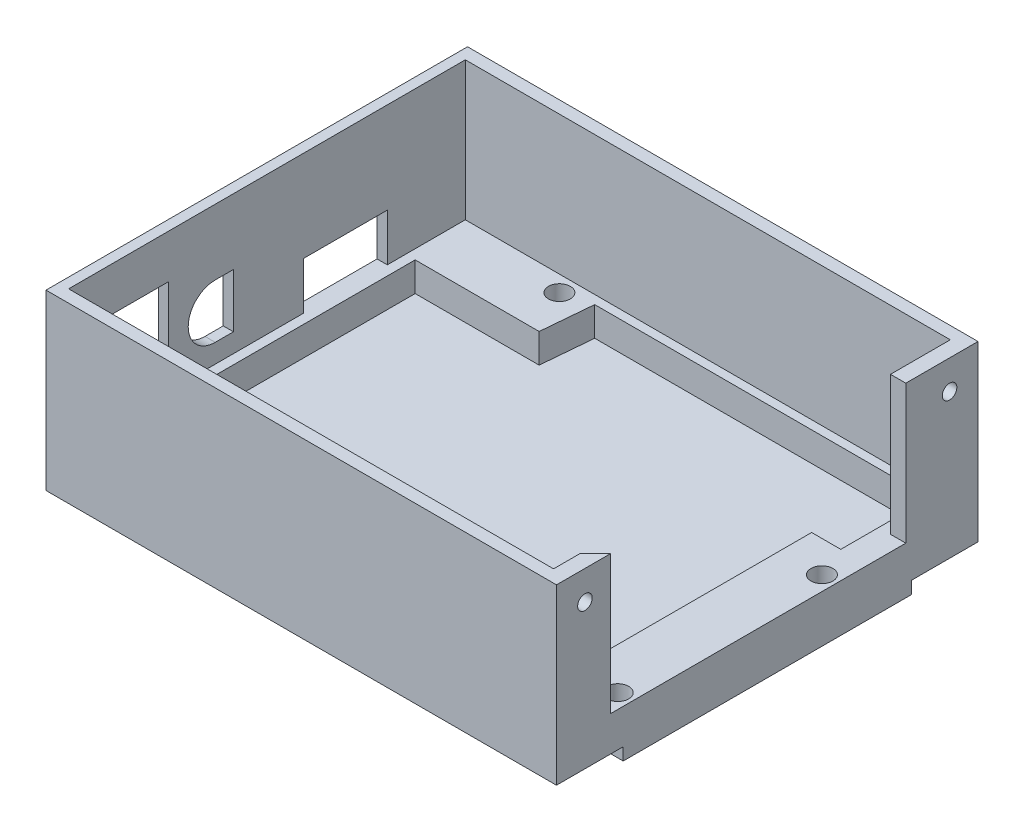
from build123d import *

# Parameters (mm, degrees)
EXTRUDE_1_DEPTH      = 4
SKETCH_3_W           = 73
SKETCH_3_H           = 58
EXTRUDE_2_DEPTH      = 13
EXTRUDE_2_DEPTH_BACK = 4
SKETCH_4_W           = 17
SKETCH_4_H           = 7
EXTRUDE_4_DEPTH      = 4
SKETCH_5_R           = 1.5
CUT_EXTRUDE_1_DEPTH  = 4
EXTRUDE_5_DEPTH      = 4
EXTRUDE_6_DEPTH      = 4
SKETCH_8_W           = 73
SKETCH_8_H           = 58
EXTRUDE_7_DEPTH      = 1
SKETCH_9_W           = 8.5
SKETCH_9_H           = 3.5
CUT_EXTRUDE_2_DEPTH  = 2
CHAMFER_1_SIZE       = 0.5
SKETCH_10_W          = 9
SKETCH_10_H          = 12
CUT_EXTRUDE_3_DEPTH  = 2
CHAMFER_2_SIZE       = 0.5
CHAMFER_3_SIZE       = 0.5
CHAMFER_4_SIZE       = 0.5
CUT_EXTRUDE_4_DEPTH  = 2
CHAMFER_5_SIZE       = 0.5
CHAMFER_6_SIZE       = 0.5
SKETCH_21_W          = 2
SKETCH_21_H          = 58
CUT_EXTRUDE_5_DEPTH  = 19
CUT_EXTRUDE_7_DEPTH  = 13
EXTRUDE_8_DEPTH      = 6
SKETCH_36_W          = 71
SKETCH_36_H          = 39.5
EXTRUDE_9_DEPTH      = 1.5
SKETCH_39_R          = 1
CUT_EXTRUDE_9_DEPTH  = 5
SKETCH_42_W          = 9.25
SKETCH_42_H          = 0.2
CUT_EXTRUDE_10_DEPTH = 72
SKETCH_43_W          = 0.1
SKETCH_43_H          = 23.8
CUT_EXTRUDE_11_DEPTH = 72
CUT_EXTRUDE_12_DEPTH = 0.5
CUT_EXTRUDE_13_DEPTH = 0.5
SKETCH_46_W          = 66.5
SKETCH_46_H          = 54.4
SKETCH_46_W_2        = 66
SKETCH_46_H_2        = 54
CUT_EXTRUDE_14_DEPTH = 19
SKETCH_47_W          = 11.5
SKETCH_47_H          = 6.5
SKETCH_47_W_2        = 8.5
SKETCH_47_H_2        = 3.5
CUT_EXTRUDE_16_DEPTH = 7.5
CUT_EXTRUDE_17_DEPTH = 7.5
SKETCH_51_W          = 10
SKETCH_51_H          = 14.5
SKETCH_51_W_2        = 7.5
SKETCH_51_H_2        = 12
CUT_EXTRUDE_18_DEPTH = 7.5


with BuildPart() as part:
    # 草图1 → 凸台-拉伸1 (new body)
    with BuildSketch(Plane(origin=(0, 0, 0), x_dir=(1, 0, 0), z_dir=(0, 1, 0))):
        Polygon((33, -27), (-33, -27), (-33, 27), (33, 27), (33, 14), (36, 11), (36, -21), (33, -24), align=None)
        Polygon((-31.777777778, 26), (-31.777777778, -26), (31.777777778, -26), (31.777777778, -23.80800866), (35, -20.585786438), (35, 9.543812347), (35, 10.585786438), (31.777777778, 13.80800866), (31.777777778, 26), align=None, mode=Mode.SUBTRACT)
    extrude(amount=-EXTRUDE_1_DEPTH)

    # 草图3 → 凸台-拉伸2 (add, two sides)
    with BuildSketch(Plane(origin=(0, 0, 0), x_dir=(1, 0, 0), z_dir=(0, 1, 0))) as extrude_2_sk:
        with Locations((1.5, 0)):
            Rectangle(SKETCH_3_W, SKETCH_3_H)
        Polygon((33, 27), (33, 14), (36, 11), (36, -21), (33, -24), (33, -27), (-33, -27), (-33, 27), align=None, mode=Mode.SUBTRACT)
    extrude(amount=EXTRUDE_2_DEPTH)
    extrude(extrude_2_sk.sketch, amount=-EXTRUDE_2_DEPTH_BACK)

    # 草图4 → 凸台-拉伸4 (add)
    with BuildSketch(Plane(origin=(0, 0, 0), x_dir=(1, 0, 0), z_dir=(0, 1, 0))):
        with Locations((-23.277777778, 22.5)):
            Rectangle(SKETCH_4_W, SKETCH_4_H)
        Polygon((31.777777778, 13.80800866), (27.777777778, 13.80800866), (27.777777778, -22), (33.585786438, -22), (35, -20.585786438), (35, 10.585786438), align=None)
    extrude(amount=-EXTRUDE_4_DEPTH)

    # 草图5 → 切除-拉伸1 (cut)
    with BuildSketch(Plane(origin=(0, 0, 0), x_dir=(1, 0, 0), z_dir=(0, 1, 0))):
        with Locations((-18, 25)):
            Circle(SKETCH_5_R)
        with Locations((33.5, 9.5)):
            Circle(SKETCH_5_R)
        with Locations((33.5, -18.5)):
            Circle(SKETCH_5_R)
    extrude(amount=-CUT_EXTRUDE_1_DEPTH, mode=Mode.SUBTRACT)

    # 草图6 → 凸台-拉伸5 (add)
    with BuildSketch(Plane.XZ.offset(4)):
        Polygon((31.777777778, 23.80800866), (33.585786438, 22), (30.681782108, 22), align=None)
    extrude(amount=-EXTRUDE_5_DEPTH)

    # 草图7 → 凸台-拉伸6 (add)
    with BuildSketch(Plane(origin=(0, 0, 0), x_dir=(1, 0, 0), z_dir=(0, 1, 0))):
        Polygon((-14.158955627, 26), (-14.777777778, 19), (-14.777777778, 26), align=None)
    extrude(amount=-EXTRUDE_6_DEPTH)

    # 草图8 → 凸台-拉伸7 (add)
    with BuildSketch(Plane.XZ.offset(4)):
        with Locations((1.5, 0)):
            Rectangle(SKETCH_8_W, SKETCH_8_H)
    extrude(amount=EXTRUDE_7_DEPTH)

    # 草图9 → 切除-拉伸2 (cut)
    with BuildSketch(Plane(origin=(-33, 0, 0), x_dir=(0, 0, -1), z_dir=(1, 0, 0))):
        with Locations((10.25, 2.75)):
            Rectangle(SKETCH_9_W, SKETCH_9_H)
    extrude(amount=-CUT_EXTRUDE_2_DEPTH, mode=Mode.SUBTRACT)

    # 倒角1
    chamfer_1_edges = [part.edges().sort_by_distance(p)[0] for p in [
        (-35, 4.5, -10.25),
        (-35, 2.75, -14.5),
        (-35, 1, -10.25),
        (-35, 2.75, -6),
    ]]
    chamfer(chamfer_1_edges, length=CHAMFER_1_SIZE)

    # 草图10 → 切除-拉伸3 (cut)
    with BuildSketch(Plane(origin=(-33, 0, 0), x_dir=(0, 0, -1), z_dir=(1, 0, 0))):
        with Locations((-18.5, 6)):
            Rectangle(SKETCH_10_W, SKETCH_10_H)
    extrude(amount=-CUT_EXTRUDE_3_DEPTH, mode=Mode.SUBTRACT)

    # 倒角2
    chamfer_2_edges = [part.edges().sort_by_distance(p)[0] for p in [
        (-35, 6, 23),
        (-35, 12, 18.5),
        (-35, 6, 14),
        (-35, 0, 18.5),
    ]]
    chamfer(chamfer_2_edges, length=CHAMFER_2_SIZE)

    # 倒角3
    chamfer_3_edges = [part.edges().sort_by_distance(p)[0] for p in [
        (-33, 4.5, -10.25),
        (-33, 1, -10.25),
        (-33, 12, 18.5),
    ]]
    chamfer(chamfer_3_edges, length=CHAMFER_3_SIZE)

    # 倒角4
    chamfer_4_edges = [part.edges().sort_by_distance(p)[0] for p in [
        (-33, 6, 14),
        (-33, 6, 23),
        (-33, 2.75, -6),
        (-33, 2.75, -14.5),
    ]]
    chamfer(chamfer_4_edges, length=CHAMFER_4_SIZE)

    # 草图13 → 切除-拉伸4 (cut)
    with BuildSketch(Plane(origin=(-33, 0, 0), x_dir=(0, 0, -1), z_dir=(1, 0, 0))):
        with BuildLine():
            Line((-6, 8.6), (-7.1, 8.6))
            ThreePointArc((-7.1, 8.6), (-9.4, 6.3), (-7.1, 4))
            Line((-7.1, 4), (-6, 4))
            Line((-6, 4), (-6, 8.6))
        make_face()
    extrude(amount=-CUT_EXTRUDE_4_DEPTH, mode=Mode.SUBTRACT)

    # 倒角5
    chamfer_5_edges = [part.edges().sort_by_distance(p)[0] for p in [
        (-35, 6.3, 6),
        (-35, 4, 6.55),
        (-35, 6.3, 9.4),
        (-35, 8.6, 6.55),
    ]]
    chamfer(chamfer_5_edges, length=CHAMFER_5_SIZE)

    # 倒角6
    chamfer_6_edges = [part.edges().sort_by_distance(p)[0] for p in [
        (-33, 6.3, 6),
        (-33, 8.6, 6.55),
        (-33, 6.3, 9.4),
        (-33, 4, 6.55),
    ]]
    chamfer(chamfer_6_edges, length=CHAMFER_6_SIZE)

    # 草图21 → 切除-拉伸5 (cut, through all)
    with BuildSketch(Plane(origin=(0, 13, 0), x_dir=(1, 0, 0), z_dir=(0, 1, 0))):
        with Locations((37, 0)):
            Rectangle(SKETCH_21_W, SKETCH_21_H)
    extrude(amount=-CUT_EXTRUDE_5_DEPTH, mode=Mode.SUBTRACT)

    # 草图23 → 切除-拉伸7 (cut)
    with BuildSketch(Plane(origin=(0, 13, 0), x_dir=(1, 0, 0), z_dir=(0, 1, 0))):
        Polygon((33, 14), (33, 19), (36, 19), (36, 11), align=None)
    extrude(amount=-CUT_EXTRUDE_7_DEPTH, mode=Mode.SUBTRACT)

    # 草图27 → 凸台-拉伸8 (add)
    with BuildSketch(Plane(origin=(0, 13, 0), x_dir=(1, 0, 0), z_dir=(0, 1, 0))):
        Polygon((33, 19), (36, 19), (36, 29), (-35, 29), (-35, -29), (36, -29), (36, -21), (33, -24), (33, -27), (-33, -27), (-33, 27), (33, 27), align=None)
    extrude(amount=EXTRUDE_8_DEPTH)

    # 草图36 → 凸台-拉伸9 (add)
    with BuildSketch(Plane.XZ.offset(5)):
        with Locations((0.5, 0)):
            Rectangle(SKETCH_36_W, SKETCH_36_H)
    extrude(amount=EXTRUDE_9_DEPTH)

    # 草图39 → 切除-拉伸9 (cut)
    with BuildSketch(Plane(origin=(36, 0, 0), x_dir=(0, 0, -1), z_dir=(1, 0, 0))):
        with Locations((-25, 15)):
            Circle(SKETCH_39_R)
        with Locations((25, 15)):
            Circle(SKETCH_39_R)
    extrude(amount=-CUT_EXTRUDE_9_DEPTH, mode=Mode.SUBTRACT)

    # 草图42 → 切除-拉伸10 (cut, through all)
    with BuildSketch(Plane(origin=(36, 0, 0), x_dir=(0, 0, -1), z_dir=(1, 0, 0))):
        with Locations((-24.375, -4.9)):
            Rectangle(SKETCH_42_W, SKETCH_42_H)
        with Locations((24.375, -4.9)):
            Rectangle(SKETCH_42_W, SKETCH_42_H)
    extrude(amount=-CUT_EXTRUDE_10_DEPTH, mode=Mode.SUBTRACT)

    # 草图43 → 切除-拉伸11 (cut, through all)
    with BuildSketch(Plane(origin=(36, 0, 0), x_dir=(0, 0, -1), z_dir=(1, 0, 0))):
        with Locations((-28.95, 7.1)):
            Rectangle(SKETCH_43_W, SKETCH_43_H)
        with Locations((28.95, 7.1)):
            Rectangle(SKETCH_43_W, SKETCH_43_H)
    extrude(amount=-CUT_EXTRUDE_11_DEPTH, mode=Mode.SUBTRACT)

    # 草图44 → 切除-拉伸12 (cut)
    with BuildSketch(Plane(origin=(36, 0, 0), x_dir=(0, 0, -1), z_dir=(1, 0, 0))):
        Polygon((19.75, -4.8), (28.9, -4.8), (28.9, 19), (19, 19), (19, 0), (-21, 0), (-21, 19), (-28.9, 19), (-28.9, -4.8), (-19.75, -4.8), (-19.75, -6.5), (19.75, -6.5), align=None)
    extrude(amount=-CUT_EXTRUDE_12_DEPTH, mode=Mode.SUBTRACT)

    # 草图45 → 切除-拉伸13 (cut)
    with BuildSketch(Plane.ZY.offset(35)):
        Polygon((28.9, 19), (-28.9, 19), (-28.9, -4.8), (-19.75, -4.8), (-19.75, -6.5), (19.75, -6.5), (19.75, -4.8), (28.9, -4.8), align=None)
    extrude(amount=-CUT_EXTRUDE_13_DEPTH, mode=Mode.SUBTRACT)

    # 草图46 → 切除-拉伸14 (cut)
    with BuildSketch(Plane(origin=(0, 19, 0), x_dir=(1, 0, 0), z_dir=(0, 1, 0))):
        with Locations((0.15, 0)):
            Rectangle(SKETCH_46_W, SKETCH_46_H)
        Rectangle(SKETCH_46_W_2, SKETCH_46_H_2, mode=Mode.SUBTRACT)
    extrude(amount=-CUT_EXTRUDE_14_DEPTH, mode=Mode.SUBTRACT)

    # 草图47 → 切除-拉伸16 (cut)
    with BuildSketch(Plane.ZY.offset(34.5)):
        with Locations((-10.75, 3.25)):
            Rectangle(SKETCH_47_W, SKETCH_47_H)
        with Locations((-10.25, 2.75)):
            Rectangle(SKETCH_47_W_2, SKETCH_47_H_2, mode=Mode.SUBTRACT)
    extrude(amount=-CUT_EXTRUDE_16_DEPTH, mode=Mode.SUBTRACT)

    # 草图48 → 切除-拉伸17 (cut)
    with BuildSketch(Plane(origin=(-33.1, 0, 0), x_dir=(0, 0, -1), z_dir=(1, 0, 0))):
        with BuildLine():
            Line((-7.1, 10), (-5.6, 10))
            Line((-5.6, 10), (-4.6, 10))
            Line((-4.6, 10), (-4.6, 2.6))
            Line((-4.6, 2.6), (-5.6, 2.6))
            Line((-5.6, 2.6), (-7.1, 2.6))
            ThreePointArc((-7.1, 2.6), (-10.8, 6.3), (-7.1, 10))
        make_face()
    extrude(amount=-CUT_EXTRUDE_17_DEPTH, mode=Mode.SUBTRACT)

    # 草图51 → 切除-拉伸18 (cut)
    with BuildSketch(Plane.ZY.offset(34.5)):
        with Locations((18.5, 5.75)):
            Rectangle(SKETCH_51_W, SKETCH_51_H)
        with Locations((17.75, 6)):
            Rectangle(SKETCH_51_W_2, SKETCH_51_H_2, mode=Mode.SUBTRACT)
    extrude(amount=-CUT_EXTRUDE_18_DEPTH, mode=Mode.SUBTRACT)


solid = part.part
